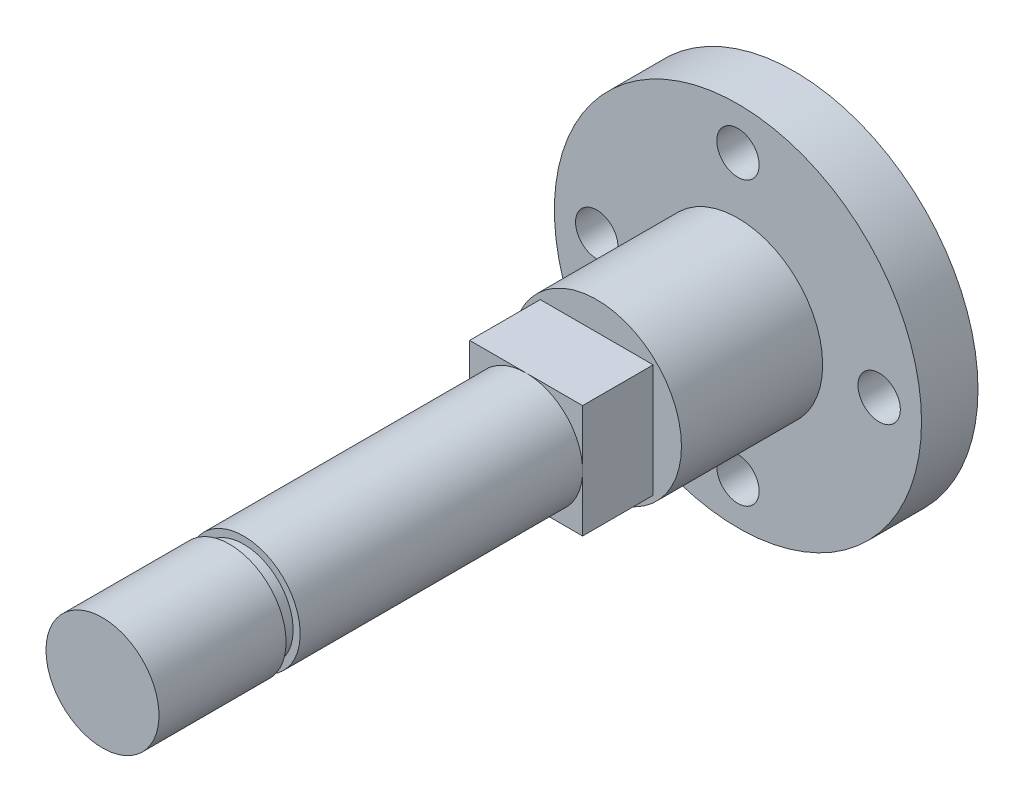
from build123d import *

# Parameters (mm, degrees)
SKETCH1_R           = 13
BOSS_EXTRUDE1_DEPTH = 4
SKETCH2_R           = 7.25
CUT_EXTRUDE1_DEPTH  = 3
SKETCH3_R           = 1.5
CUT_EXTRUDE2_DEPTH  = 5
SKETCH6_R           = 6
BOSS_EXTRUDE5_DEPTH = 10
BOSS_EXTRUDE4_START = 10
SKETCH5_W           = 8
SKETCH5_H           = 8
BOSS_EXTRUDE4_DEPTH = 5
BOSS_EXTRUDE3_START = 15
SKETCH4_R           = 4
BOSS_EXTRUDE3_DEPTH = 30
SKETCH10_W          = 2
SKETCH10_H          = 1


with BuildPart() as part:
    # Sketch1 → Boss-Extrude1 (new body)
    with BuildSketch(Plane.XY):
        Circle(SKETCH1_R)
    extrude(amount=BOSS_EXTRUDE1_DEPTH)

    # Sketch2 → Cut-Extrude1 (cut)
    with BuildSketch(Plane(origin=(0, 0, 0), x_dir=(-1, 0, 0), z_dir=(0, 0, -1))):
        Circle(SKETCH2_R)
    extrude(amount=-CUT_EXTRUDE1_DEPTH, mode=Mode.SUBTRACT)

    # Sketch3 → Cut-Extrude2 (cut, through all)
    with BuildSketch(Plane.XY.offset(4)):
        with Locations((0, 10)):
            Circle(SKETCH3_R)
        with Locations((10, 0)):
            Circle(SKETCH3_R)
        with Locations((0, -10)):
            Circle(SKETCH3_R)
        with Locations((-10, 0)):
            Circle(SKETCH3_R)
    extrude(amount=-CUT_EXTRUDE2_DEPTH, mode=Mode.SUBTRACT)

    # Sketch6 → Boss-Extrude5 (add)
    with BuildSketch(Plane.XY.offset(4)):
        Circle(SKETCH6_R)
    extrude(amount=BOSS_EXTRUDE5_DEPTH)

    # Sketch5 → Boss-Extrude4 (add)
    with BuildSketch(Plane.XY.offset(4).offset(BOSS_EXTRUDE4_START)):
        Rectangle(SKETCH5_W, SKETCH5_H)
    extrude(amount=BOSS_EXTRUDE4_DEPTH)

    # Sketch4 → Boss-Extrude3 (add)
    with BuildSketch(Plane.XY.offset(4).offset(BOSS_EXTRUDE3_START)):
        Circle(SKETCH4_R)
    extrude(amount=BOSS_EXTRUDE3_DEPTH)

    # Sketch10 → Cut-Revolve1 (revolve, cut)
    with BuildSketch(Plane(origin=(0, 0, 0), x_dir=(1, 0, 0), z_dir=(0, 1, 0))):
        with Locations((-4.5, -39.5)):
            Rectangle(SKETCH10_W, SKETCH10_H)
    revolve(axis=Axis((0, 0, 0), (0, 0, 1)), mode=Mode.SUBTRACT)


solid = part.part
